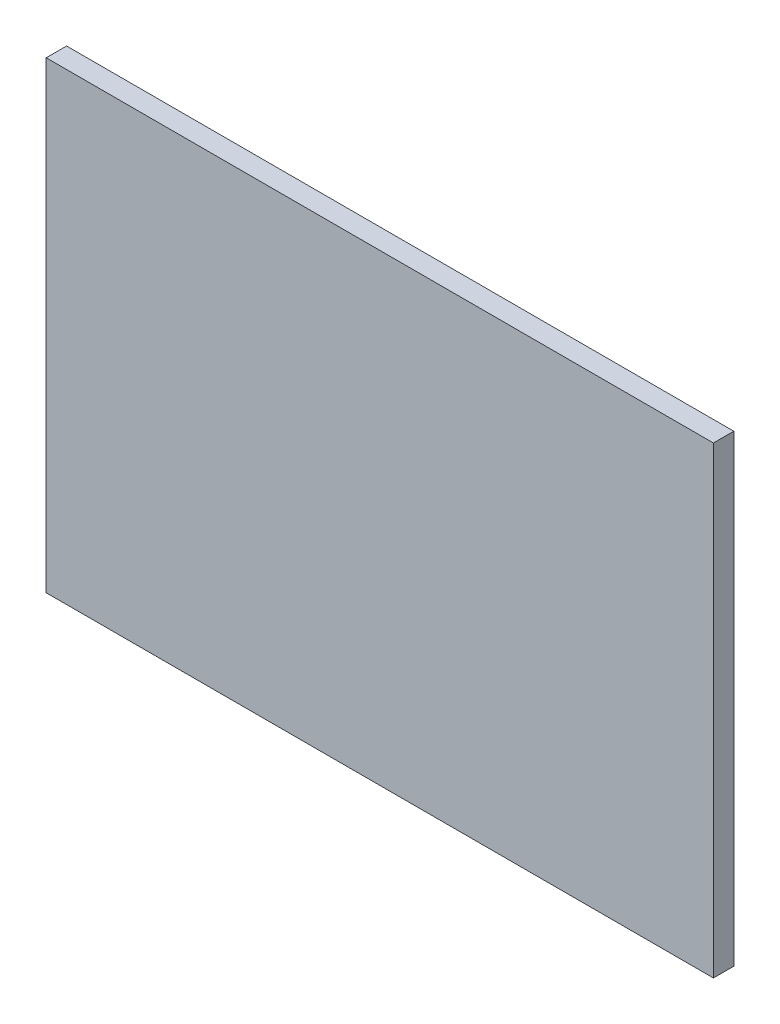
from build123d import *

# Parameters (mm, degrees)
SKETCH_1_W      = 36
SKETCH_1_H      = 25
EXTRUDE_1_DEPTH = 1.1


with BuildPart() as part:
    # 草图1 → 凸台-拉伸1 (new body)
    with BuildSketch(Plane.XY):
        Rectangle(SKETCH_1_W, SKETCH_1_H)
    extrude(amount=EXTRUDE_1_DEPTH)


solid = part.part
